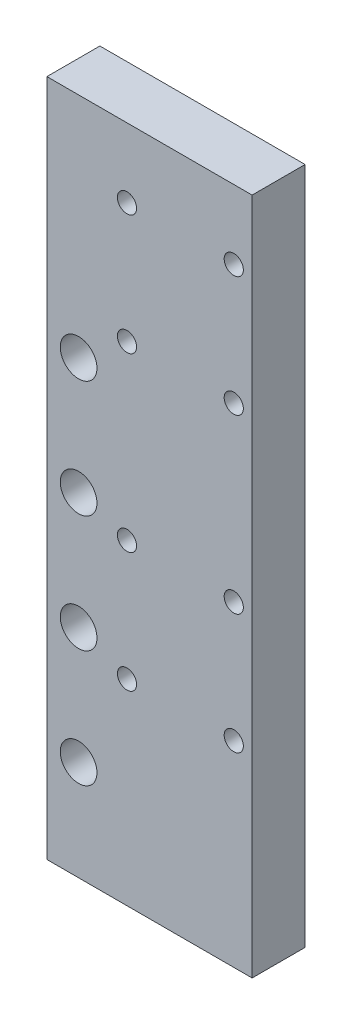
from build123d import *

# Parameters (mm, degrees)
SKETCH1_W           = 61.5
SKETCH1_H           = 203.2
BOSS_EXTRUDE1_DEPTH = 7.9375
SKETCH2_R           = 5.5
CUT_EXTRUDE1_DEPTH  = 16.875
SKETCH3_R           = 2.875
CUT_EXTRUDE2_DEPTH  = 16.875
LPATTERN1_COUNT     = 2
LPATTERN1_PITCH     = 32


with BuildPart() as part:
    # Sketch1 → Boss-Extrude1 (new body, symmetric)
    with BuildSketch(Plane.XY):
        Rectangle(SKETCH1_W, SKETCH1_H)
    extrude(amount=BOSS_EXTRUDE1_DEPTH, both=True)

    # Sketch2 → Cut-Extrude1 (cut, through all)
    with BuildSketch(Plane.XY.offset(7.9375)):
        with Locations((-21.25, 33.4)):
            Circle(SKETCH2_R)
        with Locations((-21.25, -1.6)):
            Circle(SKETCH2_R)
        with Locations((-21.25, -36.6)):
            Circle(SKETCH2_R)
        with Locations((-21.25, -71.6)):
            Circle(SKETCH2_R)
    extrude(amount=-CUT_EXTRUDE1_DEPTH, mode=Mode.SUBTRACT)

    # Sketch3 → Cut-Extrude2 (cut, through all)
    with BuildSketch(Plane.XY.offset(7.9375)):
        with Locations((-6.75, 80.85)):
            Circle(SKETCH3_R)
        with Locations((-6.75, 44.85)):
            Circle(SKETCH3_R)
        with Locations((-6.75, -6.75)):
            Circle(SKETCH3_R)
        with Locations((-6.75, -42.75)):
            Circle(SKETCH3_R)
    cut_extrude2 = extrude(amount=-CUT_EXTRUDE2_DEPTH, mode=Mode.SUBTRACT)

    # LPattern1: Cut-Extrude2 ×2
    with Locations(*[(i * LPATTERN1_PITCH, 0, 0) for i in range(1, LPATTERN1_COUNT)]):
        add(cut_extrude2, mode=Mode.SUBTRACT)


solid = part.part
